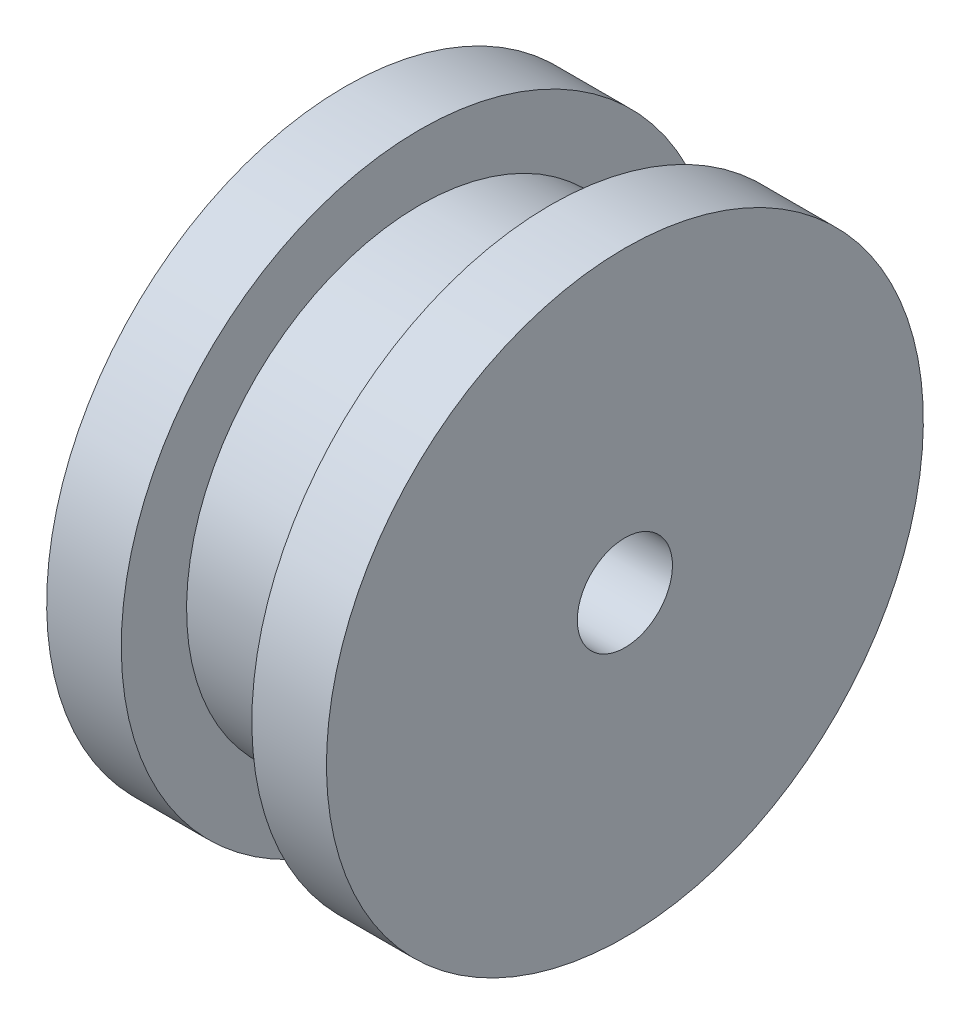
from build123d import *

# Parameters (mm, degrees)
SKETCH2_R          = 2.55
CUT_EXTRUDE1_DEPTH = 15


with BuildPart() as part:
    # Sketch1 → Revolve1 (revolve)
    with BuildSketch(Plane.XY):
        Polygon((0, 0), (0, 16), (4, 16), (4, 12.5), (11, 12.5), (11, 16), (15, 16), (15, 0), align=None)
    revolve(axis=Axis((15, 0, 0), (-1, 0, 0)))

    # Sketch2 → Cut-Extrude1 (cut)
    with BuildSketch(Plane.ZY):
        Circle(SKETCH2_R)
    extrude(amount=-CUT_EXTRUDE1_DEPTH, mode=Mode.SUBTRACT)


solid = part.part
